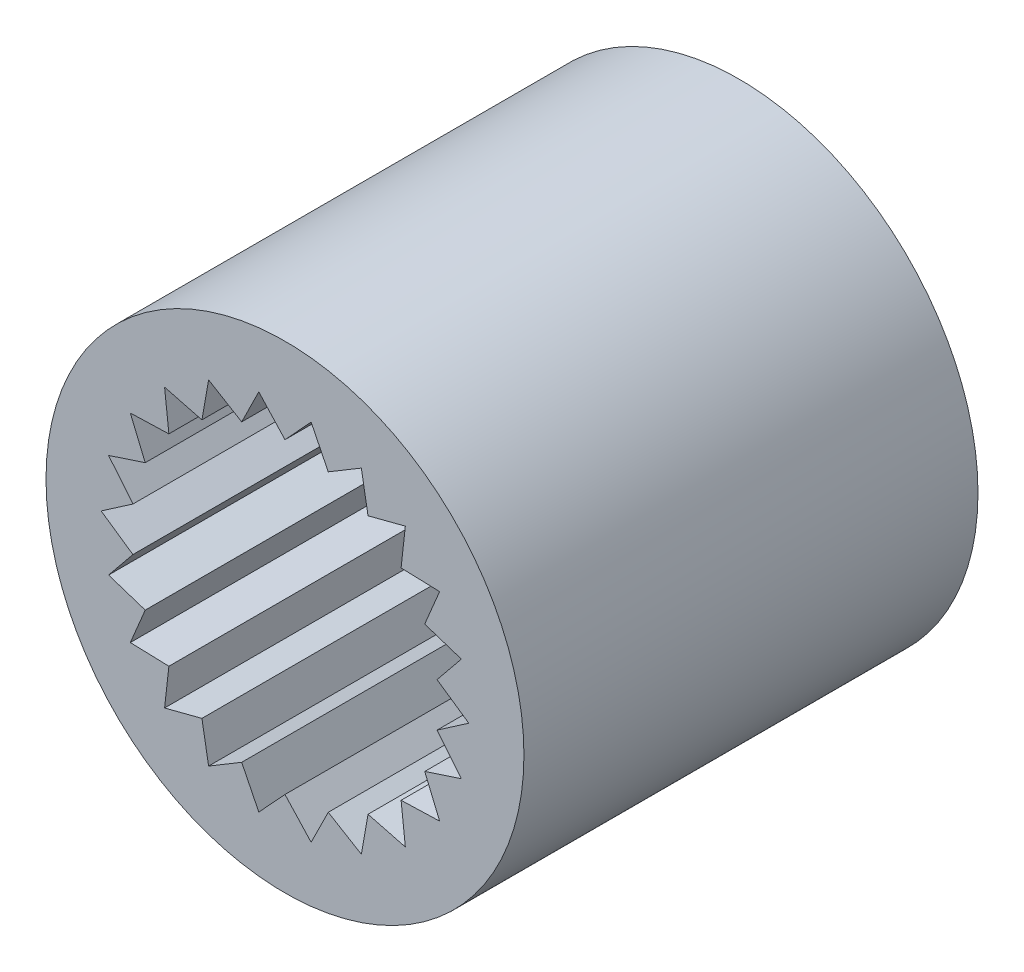
from build123d import *

# Parameters (mm, degrees)
SKETCH1_W          = 3.5
SKETCH1_H          = 6.65
CUT_EXTRUDE1_DEPTH = 9
CUT_EXTRUDE3_DEPTH = 10


with BuildPart() as part:
    # Sketch1 → Revolve1 (revolve)
    with BuildSketch(Plane(origin=(0, 0, 0), x_dir=(1, 0, 0), z_dir=(0, 1, 0))):
        with Locations((1.75, -3.325)):
            Rectangle(SKETCH1_W, SKETCH1_H)
    revolve(axis=Axis((0, 0, 0), (0, 0, 1)))

    # Sketch3 → Cut-Extrude1 (cut)
    with BuildSketch(Plane.XY.offset(6.65)):
        Polygon((2.06028803, 1.324066719), (1.700436542, 1.473436651), (1.603799186, 1.850882928), (1.216441839, 1.892820449), (1.017380071, 2.227751609), (0.633898253, 2.158859191), (0.348538872, 2.424141105), (0, 2.25), (-0.348538872, 2.424141105), (-0.633898253, 2.158859191), (-1.017380071, 2.227751609), (-1.216441839, 1.892820449), (-1.603799186, 1.850882928), (-1.700436542, 1.473436651), (-2.06028803, 1.324066719), (-2.04667199, 0.934683779), (-2.34986459, 0.689982499), (-2.227098244, 0.320208386), (-2.449069097, 0), (-2.227098244, -0.320208386), (-2.34986459, -0.689982499), (-2.04667199, -0.934683779), (-2.06028803, -1.324066719), (-1.700436542, -1.473436651), (-1.603799186, -1.850882928), (-1.216441839, -1.892820449), (-1.017380071, -2.227751609), (-0.633898253, -2.158859191), (-0.348538872, -2.424141105), (0, -2.25), (0.348538872, -2.424141105), (0.633898253, -2.158859191), (1.017380071, -2.227751609), (1.216441839, -1.892820449), (1.603799186, -1.850882928), (1.700436542, -1.473436651), (2.06028803, -1.324066719), (2.04667199, -0.934683779), (2.34986459, -0.689982499), (2.227098244, -0.320208386), (2.449069097, 0), (2.227098244, 0.320208386), (2.34986459, 0.689982499), (2.04667199, 0.934683779), align=None)
    extrude(amount=-CUT_EXTRUDE1_DEPTH, mode=Mode.SUBTRACT)

    # Sketch9 → Cut-Extrude3 (cut)
    with BuildSketch(Plane.XY.offset(6.65)):
        Polygon((0, -2.25), (0.383171844, -2.665018714), (0.633898253, -2.158859191), (1.118473228, -2.449114747), (1.216441839, -1.892820449), (1.763162563, -2.034798069), (1.700436542, -1.473436651), (2.265010954, -1.455634153), (2.04667199, -0.934683779), (2.583361627, -0.758543414), (2.227098244, -0.320208386), (2.692423705, 0), (2.227098244, 0.320208386), (2.583361627, 0.758543414), (2.04667199, 0.934683779), (2.265010954, 1.455634153), (1.700436542, 1.473436651), (1.763162563, 2.034798069), (1.216441839, 1.892820449), (1.118473228, 2.449114747), (0.633898253, 2.158859191), (0.383171844, 2.665018714), (0, 2.25), (-0.383171844, 2.665018714), (-0.633898253, 2.158859191), (-1.118473228, 2.449114747), (-1.216441839, 1.892820449), (-1.763162563, 2.034798069), (-1.700436542, 1.473436651), (-2.265010954, 1.455634153), (-2.04667199, 0.934683779), (-2.583361627, 0.758543414), (-2.227098244, 0.320208386), (-2.692423705, 0), (-2.227098244, -0.320208386), (-2.583361627, -0.758543414), (-2.04667199, -0.934683779), (-2.265010954, -1.455634153), (-1.700436542, -1.473436651), (-1.763162563, -2.034798069), (-1.216441839, -1.892820449), (-1.118473228, -2.449114747), (-0.633898253, -2.158859191), (-0.383171844, -2.665018714), align=None)
    extrude(amount=-CUT_EXTRUDE3_DEPTH, mode=Mode.SUBTRACT)


solid = part.part
